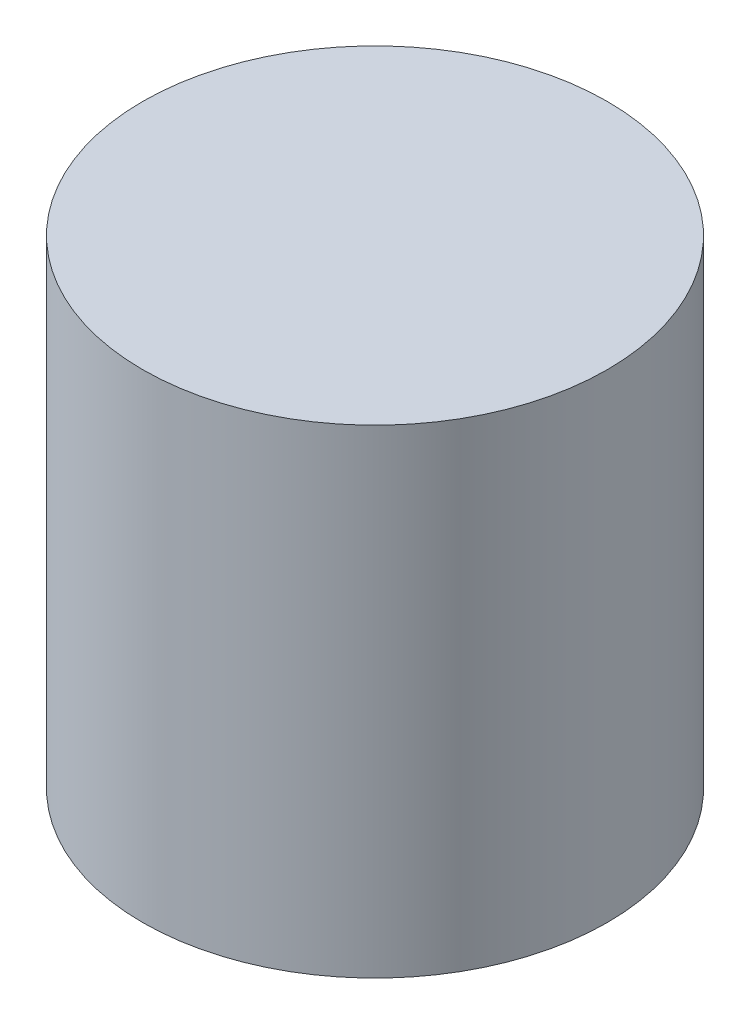
from build123d import *

# Parameters (mm, degrees)
SKETCH1_R           = 49
BOSS_EXTRUDE1_DEPTH = 101


with BuildPart() as part:
    # Sketch1 → Boss-Extrude1 (new body)
    with BuildSketch(Plane(origin=(0, -47.75, 0), x_dir=(-1, 0, 0), z_dir=(0, -1, 0))):
        with Locations((287.174494692, 235)):
            Circle(SKETCH1_R)
    extrude(amount=-BOSS_EXTRUDE1_DEPTH)


solid = part.part
